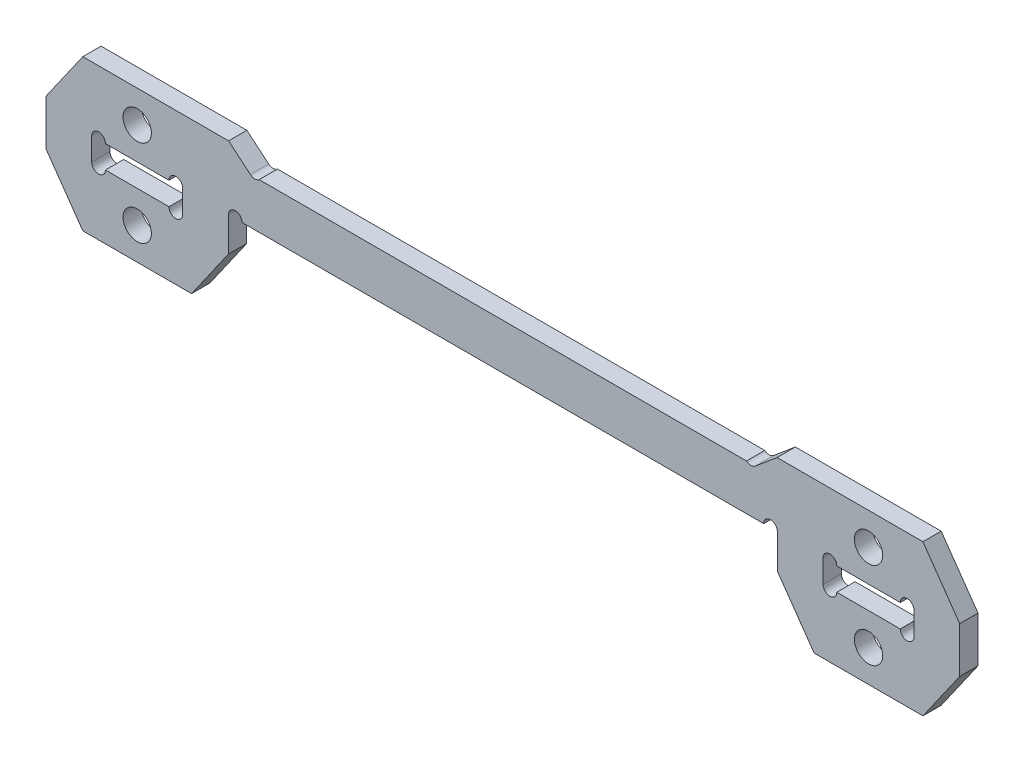
from build123d import *

# Parameters (mm, degrees)
SKETCH_1_R          = 1.55
SKETCH_1_W          = 9.95
SKETCH_1_H          = 2.5
EXTRUDE_1_DEPTH     = 1
SKETCH_2_R          = 0.75
CUT_EXTRUDE_1_DEPTH = 3
CUT_EXTRUDE_2_DEPTH = 3
SKETCH_4_R          = 0.75
CUT_EXTRUDE_3_DEPTH = 3


with BuildPart() as part:
    # 草图1 → 凸台-拉伸1 (new body, symmetric)
    with BuildSketch(Plane.XY):
        Polygon((-30.025, 1.25), (-30.025, -2.5), (-34.051193345, -8.25), (-45.948806655, -8.25), (-49.975, -2.5), (-49.975, 2.5), (-45.948806655, 8.25), (45.948806655, 8.25), (49.975, 2.5), (49.975, -2.5), (45.948806655, -8.25), (34.051193345, -8.25), (30.025, -2.5), (30.025, 1.25), align=None)
        with Locations((-40, 4.75)):
            Circle(SKETCH_1_R, mode=Mode.SUBTRACT)
        with Locations((-40, -4.75)):
            Circle(SKETCH_1_R, mode=Mode.SUBTRACT)
        with Locations((40, -4.75)):
            Circle(SKETCH_1_R, mode=Mode.SUBTRACT)
        with Locations((40, 4.75)):
            Circle(SKETCH_1_R, mode=Mode.SUBTRACT)
        with Locations((-40, 0)):
            Rectangle(SKETCH_1_W, SKETCH_1_H, mode=Mode.SUBTRACT)
        with Locations((40, 0)):
            Rectangle(SKETCH_1_W, SKETCH_1_H, mode=Mode.SUBTRACT)
    extrude(amount=EXTRUDE_1_DEPTH, both=True)

    # 草图2 → 切除-拉伸1 (cut, through all)
    with BuildSketch(Plane.XY.offset(1)):
        with Locations((-35.775, 1.25)):
            Circle(SKETCH_2_R)
        with Locations((-35.775, -1.25)):
            Circle(SKETCH_2_R)
        with Locations((-44.225, 1.25)):
            Circle(SKETCH_2_R)
        with Locations((-44.225, -1.25)):
            Circle(SKETCH_2_R)
        with Locations((-29.275, 1.25)):
            Circle(SKETCH_2_R)
        with Locations((29.275, 1.25)):
            Circle(SKETCH_2_R)
        with Locations((44.225, -1.25)):
            Circle(SKETCH_2_R)
        with Locations((44.225, 1.25)):
            Circle(SKETCH_2_R)
        with Locations((35.775, -1.25)):
            Circle(SKETCH_2_R)
        with Locations((35.775, 1.25)):
            Circle(SKETCH_2_R)
    extrude(amount=-CUT_EXTRUDE_1_DEPTH, mode=Mode.SUBTRACT)

    # 草图3 → 切除-拉伸2 (cut, through all)
    with BuildSketch(Plane.XY.offset(1)):
        Polygon((-30, 8.25), (-27.616492815, 6.25), (27.616492815, 6.25), (30, 8.25), align=None)
    extrude(amount=-CUT_EXTRUDE_2_DEPTH, mode=Mode.SUBTRACT)

    # 草图4 → 切除-拉伸3 (cut, through all)
    with BuildSketch(Plane.XY.offset(1)):
        with Locations((-27.134402108, 6.824533332)):
            Circle(SKETCH_4_R)
        with Locations((27.134402108, 6.824533332)):
            Circle(SKETCH_4_R)
    extrude(amount=-CUT_EXTRUDE_3_DEPTH, mode=Mode.SUBTRACT)


solid = part.part
